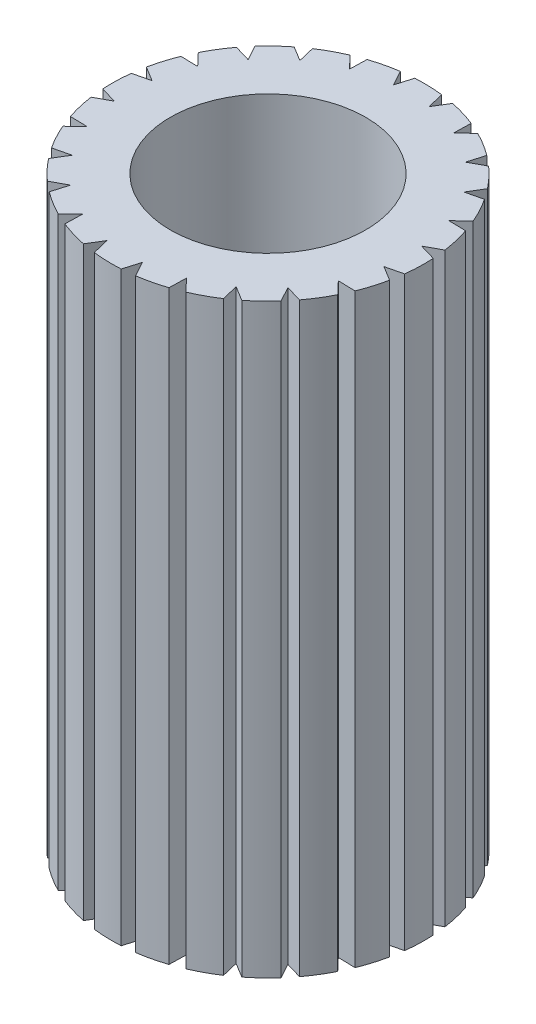
from build123d import *

# Parameters (mm, degrees)
SKETCH_1_R      = 1
EXTRUDE_1_DEPTH = 6


with BuildPart() as part:
    # 草图1 → 凸台-拉伸1 (new body)
    with BuildSketch(Plane(origin=(0, 0, 0), x_dir=(1, 0, 0), z_dir=(0, 1, 0))):
        with BuildLine():
            Line((-0.228121034, 1.583654253), (-0.144036994, 1.429143956))
            Line((-0.144036994, 1.429143956), (-0.094428358, 1.597211096))
            ThreePointArc((-0.094428358, 1.597211096), (0.047740264, 1.599287612), (0.189531883, 1.588734611))
            Line((0.189531883, 1.588734611), (0.230760622, 1.417726573))
            Line((0.230760622, 1.417726573), (0.322177861, 1.567227305))
            ThreePointArc((0.322177861, 1.567227305), (0.460039647, 1.532437119), (0.594268516, 1.485545331))
            Line((0.594268516, 1.485545331), (0.589832282, 1.309693468))
            Line((0.589832282, 1.309693468), (0.716828191, 1.430439563))
            ThreePointArc((0.716828191, 1.430439563), (0.840988088, 1.361153568), (0.958506731, 1.281118592))
            Line((0.958506731, 1.281118592), (0.908707847, 1.112406917))
            Line((0.908707847, 1.112406917), (1.062627865, 1.196169729))
            ThreePointArc((1.062627865, 1.196169729), (1.16462458, 1.097109651), (1.257424297, 0.989385738))
            Line((1.257424297, 0.989385738), (1.165656474, 0.839311673))
            Line((1.165656474, 0.839311673), (1.336011205, 0.880382905))
            ThreePointArc((1.336011205, 0.880382905), (1.408893832, 0.758299525), (1.470650475, 0.63022788))
            Line((1.470650475, 0.63022788), (1.343167539, 0.509018726))
            Line((1.343167539, 0.509018726), (1.51834759, 0.504599441))
            ThreePointArc((1.51834759, 0.504599441), (1.557149298, 0.367812539), (1.583654253, 0.228121034))
            Line((1.583654253, 0.228121034), (1.429143956, 0.144036994))
            Line((1.429143956, 0.144036994), (1.597211096, 0.094428358))
            ThreePointArc((1.597211096, 0.094428358), (1.599287612, -0.047740264), (1.588734611, -0.189531883))
            Line((1.588734611, -0.189531883), (1.417726573, -0.230760622))
            Line((1.417726573, -0.230760622), (1.567227305, -0.322177861))
            ThreePointArc((1.567227305, -0.322177861), (1.532437119, -0.460039647), (1.485545331, -0.594268516))
            Line((1.485545331, -0.594268516), (1.309693468, -0.589832282))
            Line((1.309693468, -0.589832282), (1.430439563, -0.716828191))
            ThreePointArc((1.430439563, -0.716828191), (1.361153568, -0.840988088), (1.281118592, -0.958506731))
            Line((1.281118592, -0.958506731), (1.112406917, -0.908707847))
            Line((1.112406917, -0.908707847), (1.196169729, -1.062627865))
            ThreePointArc((1.196169729, -1.062627865), (1.097109651, -1.16462458), (0.989385738, -1.257424297))
            Line((0.989385738, -1.257424297), (0.839311673, -1.165656474))
            Line((0.839311673, -1.165656474), (0.880382905, -1.336011205))
            ThreePointArc((0.880382905, -1.336011205), (0.758299525, -1.408893832), (0.63022788, -1.470650475))
            Line((0.63022788, -1.470650475), (0.509018726, -1.343167539))
            Line((0.509018726, -1.343167539), (0.504599441, -1.51834759))
            ThreePointArc((0.504599441, -1.51834759), (0.367812539, -1.557149298), (0.228121034, -1.583654253))
            Line((0.228121034, -1.583654253), (0.144036994, -1.429143956))
            Line((0.144036994, -1.429143956), (0.094428358, -1.597211096))
            ThreePointArc((0.094428358, -1.597211096), (-0.047740264, -1.599287612), (-0.189531883, -1.588734611))
            Line((-0.189531883, -1.588734611), (-0.230760622, -1.417726573))
            Line((-0.230760622, -1.417726573), (-0.322177861, -1.567227305))
            ThreePointArc((-0.322177861, -1.567227305), (-0.460039647, -1.532437119), (-0.594268516, -1.485545331))
            Line((-0.594268516, -1.485545331), (-0.589832282, -1.309693468))
            Line((-0.589832282, -1.309693468), (-0.716828191, -1.430439563))
            ThreePointArc((-0.716828191, -1.430439563), (-0.840988088, -1.361153568), (-0.958506731, -1.281118592))
            Line((-0.958506731, -1.281118592), (-0.908707847, -1.112406917))
            Line((-0.908707847, -1.112406917), (-1.062627865, -1.196169729))
            ThreePointArc((-1.062627865, -1.196169729), (-1.16462458, -1.097109651), (-1.257424297, -0.989385738))
            Line((-1.257424297, -0.989385738), (-1.165656474, -0.839311673))
            Line((-1.165656474, -0.839311673), (-1.336011205, -0.880382905))
            ThreePointArc((-1.336011205, -0.880382905), (-1.408893832, -0.758299525), (-1.470650475, -0.63022788))
            Line((-1.470650475, -0.63022788), (-1.343167539, -0.509018726))
            Line((-1.343167539, -0.509018726), (-1.51834759, -0.504599441))
            ThreePointArc((-1.51834759, -0.504599441), (-1.557149298, -0.367812539), (-1.583654253, -0.228121034))
            Line((-1.583654253, -0.228121034), (-1.429143956, -0.144036994))
            Line((-1.429143956, -0.144036994), (-1.597211096, -0.094428358))
            ThreePointArc((-1.597211096, -0.094428358), (-1.599287612, 0.047740264), (-1.588734611, 0.189531883))
            Line((-1.588734611, 0.189531883), (-1.417726573, 0.230760622))
            Line((-1.417726573, 0.230760622), (-1.567227305, 0.322177861))
            ThreePointArc((-1.567227305, 0.322177861), (-1.532437119, 0.460039647), (-1.485545331, 0.594268516))
            Line((-1.485545331, 0.594268516), (-1.309693468, 0.589832282))
            Line((-1.309693468, 0.589832282), (-1.430439563, 0.716828191))
            ThreePointArc((-1.430439563, 0.716828191), (-1.361153568, 0.840988088), (-1.281118592, 0.958506731))
            Line((-1.281118592, 0.958506731), (-1.112406917, 0.908707847))
            Line((-1.112406917, 0.908707847), (-1.196169729, 1.062627865))
            ThreePointArc((-1.196169729, 1.062627865), (-1.097109651, 1.16462458), (-0.989385738, 1.257424297))
            Line((-0.989385738, 1.257424297), (-0.839311673, 1.165656474))
            Line((-0.839311673, 1.165656474), (-0.880382905, 1.336011205))
            ThreePointArc((-0.880382905, 1.336011205), (-0.758299525, 1.408893832), (-0.63022788, 1.470650475))
            Line((-0.63022788, 1.470650475), (-0.509018726, 1.343167539))
            Line((-0.509018726, 1.343167539), (-0.504599441, 1.51834759))
            ThreePointArc((-0.504599441, 1.51834759), (-0.367812539, 1.557149298), (-0.228121034, 1.583654253))
        make_face()
        Circle(SKETCH_1_R, mode=Mode.SUBTRACT)
    extrude(amount=EXTRUDE_1_DEPTH)


solid = part.part
